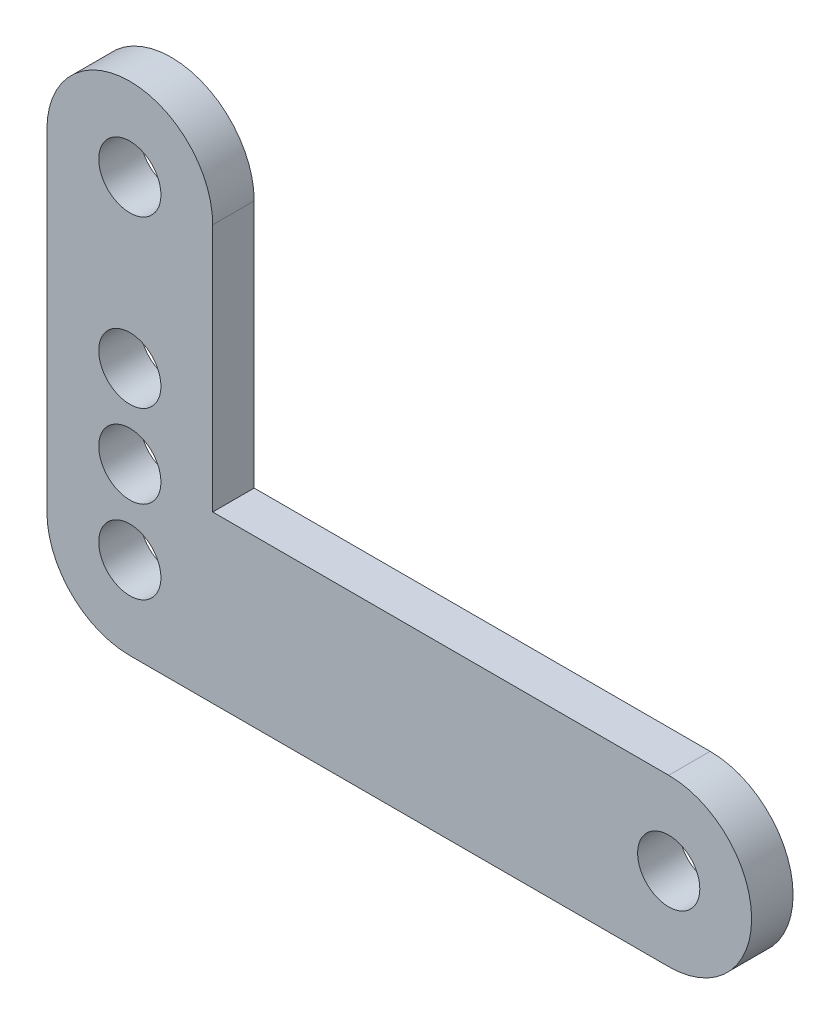
from build123d import *

# Parameters (mm, degrees)
SKETCH1_R           = 4.7625
BOSS_EXTRUDE1_DEPTH = 6.35


with BuildPart() as part:
    # Sketch1 → Boss-Extrude1 (new body)
    with BuildSketch(Plane.XY):
        with BuildLine():
            Line((-82.55, -12.7), (0, -12.7))
            ThreePointArc((0, -12.7), (12.7, 0), (0, 12.7))
            Line((0, 12.7), (-69.85, 12.7))
            Line((-69.85, 12.7), (-69.85, 50.8))
            ThreePointArc((-69.85, 50.8), (-82.55, 63.5), (-95.25, 50.8))
            Line((-95.25, 50.8), (-95.25, 0))
            ThreePointArc((-95.25, 0), (-91.530256121, -8.980256121), (-82.55, -12.7))
        make_face()
        with Locations((-82.55, 12.7)):
            Circle(SKETCH1_R, mode=Mode.SUBTRACT)
        Circle(SKETCH1_R, mode=Mode.SUBTRACT)
        with Locations((-82.55, 0)):
            Circle(SKETCH1_R, mode=Mode.SUBTRACT)
        with Locations((-82.55, 50.8)):
            Circle(SKETCH1_R, mode=Mode.SUBTRACT)
        with Locations((-82.55, 25.4)):
            Circle(SKETCH1_R, mode=Mode.SUBTRACT)
    extrude(amount=BOSS_EXTRUDE1_DEPTH)


solid = part.part
